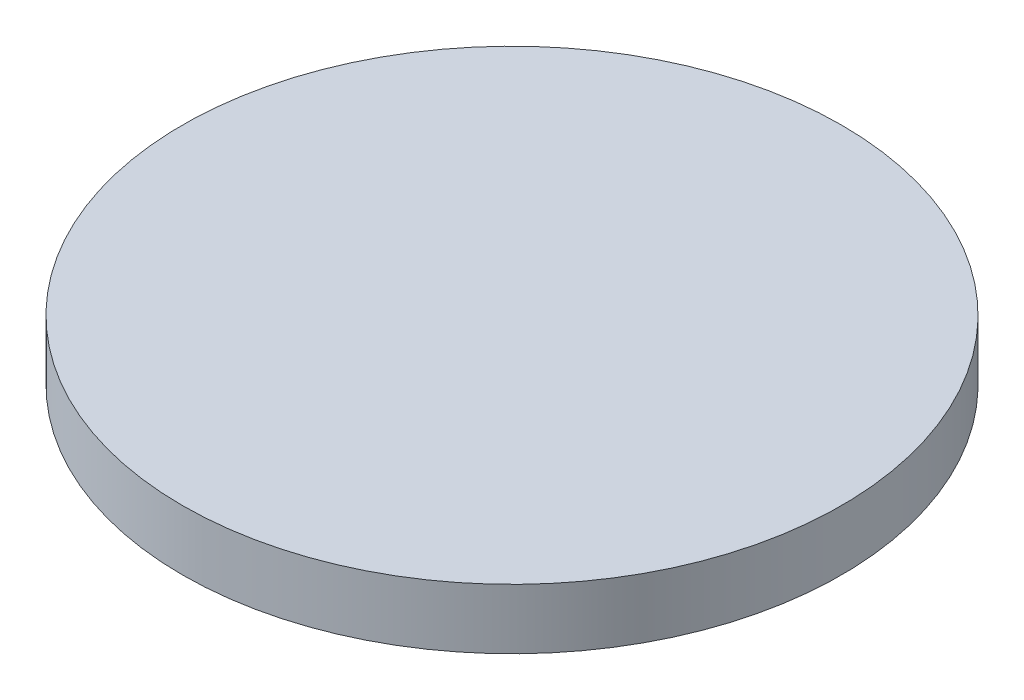
from build123d import *

# Parameters (mm, degrees)
SKETCH2_R           = 164.446208638
BOSS_EXTRUDE3_DEPTH = 30


with BuildPart() as part:
    # Sketch2 → Boss-Extrude3 (new body)
    with BuildSketch(Plane(origin=(0, 30, 0), x_dir=(1, 0, 0), z_dir=(0, 1, 0))):
        Circle(SKETCH2_R)
    extrude(amount=BOSS_EXTRUDE3_DEPTH)


solid = part.part
